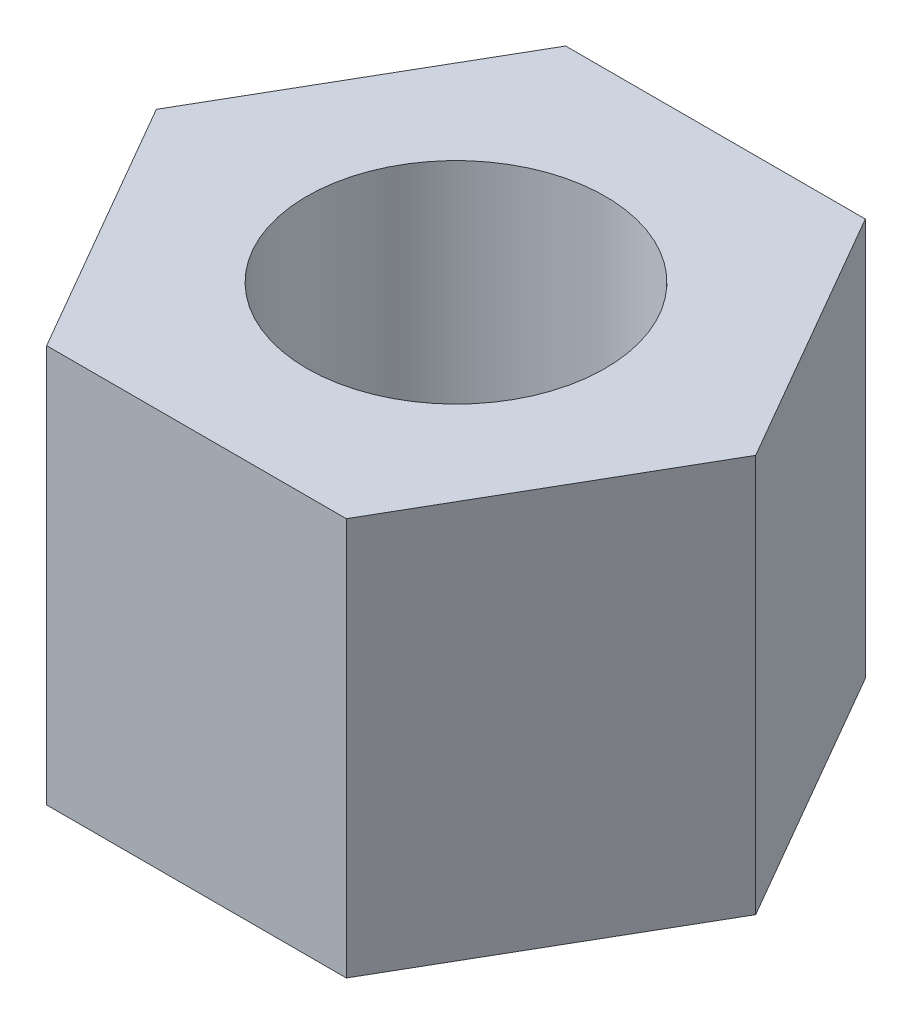
from build123d import *

# Parameters (mm, degrees)
SKETCH1_R           = 1.5
BOSS_EXTRUDE1_DEPTH = 4


with BuildPart() as part:
    # Sketch1 → Boss-Extrude1 (new body)
    with BuildSketch(Plane(origin=(0, 0, 0), x_dir=(1, 0, 0), z_dir=(0, 1, 0))):
        Polygon((3.013443115, 0), (1.506721558, 2.609718291), (-1.506721558, 2.609718291), (-3.013443115, 0), (-1.506721558, -2.609718291), (1.506721558, -2.609718291), align=None)
        Circle(SKETCH1_R, mode=Mode.SUBTRACT)
    extrude(amount=BOSS_EXTRUDE1_DEPTH)


solid = part.part
